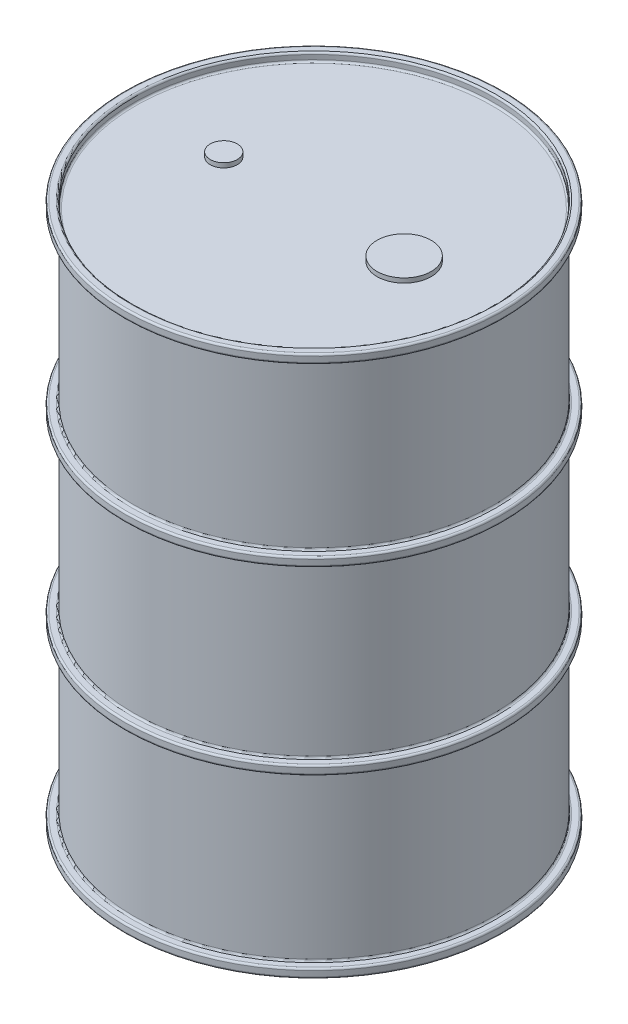
from build123d import *

# Parameters (mm, degrees)
CROQUIS1_R              = 10
SALIENTE_EXTRUIR1_DEPTH = 30
CROQUIS1_5_R            = 10.5
CROQUIS1_5_R_2          = 10
SALIENTE_EXTRUIR2_DEPTH = 0.5
SALIENTE_EXTRUIR3_START = 10
CROQUIS1_6_R            = 10.5
CROQUIS1_6_R_2          = 10
SALIENTE_EXTRUIR3_DEPTH = 0.25
SALIENTE_EXTRUIR4_START = 20
CROQUIS1_7_R            = 10.5
CROQUIS1_7_R_2          = 10
SALIENTE_EXTRUIR4_DEPTH = 0.25
SALIENTE_EXTRUIR5_START = 29.5
CROQUIS1_8_R            = 10.5
CROQUIS1_8_R_2          = 10
SALIENTE_EXTRUIR5_DEPTH = 0.5
CORTAR_EXTRUIR1_START   = -0.45
CROQUIS2_R              = 10
CORTAR_EXTRUIR1_DEPTH   = 0.45
CORTAR_EXTRUIR2_START   = -30
CROQUIS2_2_R            = 10
CORTAR_EXTRUIR2_DEPTH   = 0.45
REDONDEO2_R             = 0.1
CROQUIS3_R              = 0.75
CROQUIS3_R_2            = 1.5
SALIENTE_EXTRUIR6_DEPTH = 0.25


with BuildPart() as part:
    # Croquis1 → Saliente-Extruir1 (new body)
    with BuildSketch(Plane(origin=(0, 0, 0), x_dir=(1, 0, 0), z_dir=(0, 1, 0))):
        Circle(CROQUIS1_R)
    extrude(amount=SALIENTE_EXTRUIR1_DEPTH)

    # Croquis1_5 → Saliente-Extruir2 (add)
    with BuildSketch(Plane(origin=(0, 0, 0), x_dir=(1, 0, 0), z_dir=(0, 1, 0))):
        Circle(CROQUIS1_5_R)
        Circle(CROQUIS1_5_R_2, mode=Mode.SUBTRACT)
    extrude(amount=SALIENTE_EXTRUIR2_DEPTH)

    # Croquis1_6 → Saliente-Extruir3 (add, symmetric)
    with BuildSketch(Plane(origin=(0, 0, 0), x_dir=(1, 0, 0), z_dir=(0, 1, 0)).offset(SALIENTE_EXTRUIR3_START)):
        Circle(CROQUIS1_6_R)
        Circle(CROQUIS1_6_R_2, mode=Mode.SUBTRACT)
    extrude(amount=SALIENTE_EXTRUIR3_DEPTH, both=True)

    # Croquis1_7 → Saliente-Extruir4 (add, symmetric)
    with BuildSketch(Plane(origin=(0, 0, 0), x_dir=(1, 0, 0), z_dir=(0, 1, 0)).offset(SALIENTE_EXTRUIR4_START)):
        Circle(CROQUIS1_7_R)
        Circle(CROQUIS1_7_R_2, mode=Mode.SUBTRACT)
    extrude(amount=SALIENTE_EXTRUIR4_DEPTH, both=True)

    # Croquis1_8 → Saliente-Extruir5 (add)
    with BuildSketch(Plane(origin=(0, 0, 0), x_dir=(1, 0, 0), z_dir=(0, 1, 0)).offset(SALIENTE_EXTRUIR5_START)):
        Circle(CROQUIS1_8_R)
        Circle(CROQUIS1_8_R_2, mode=Mode.SUBTRACT)
    extrude(amount=SALIENTE_EXTRUIR5_DEPTH)

    # Croquis2 → Cortar-Extruir1 (cut)
    with BuildSketch(Plane(origin=(0, 30, 0), x_dir=(1, 0, 0), z_dir=(0, 1, 0)).offset(CORTAR_EXTRUIR1_START)):
        Circle(CROQUIS2_R)
    extrude(amount=CORTAR_EXTRUIR1_DEPTH, mode=Mode.SUBTRACT)

    # Croquis2_2 → Cortar-Extruir2 (cut)
    with BuildSketch(Plane(origin=(0, 30, 0), x_dir=(1, 0, 0), z_dir=(0, 1, 0)).offset(CORTAR_EXTRUIR2_START)):
        Circle(CROQUIS2_2_R)
    extrude(amount=CORTAR_EXTRUIR2_DEPTH, mode=Mode.SUBTRACT)

    # Redondeo2
    redondeo2_edges = [part.edges().sort_by_distance(p)[0] for p in [
        (-10, 0.45, 0),
        (-10, 0, 0),
        (-10.5, 0, 0),
        (-10.5, 0.5, 0),
        (-10, 0.5, 0),
        (-10, 9.75, 0),
        (-10.5, 9.75, 0),
        (-10.5, 10.25, 0),
        (-10, 10.25, 0),
        (-10, 19.75, 0),
        (-10.5, 19.75, 0),
        (-10.5, 20.25, 0),
        (-10, 20.25, 0),
        (-10, 29.55, 0),
        (-10, 30, 0),
        (-10.5, 30, 0),
        (-10.5, 29.5, 0),
        (-10, 29.5, 0),
    ]]
    fillet(redondeo2_edges, radius=REDONDEO2_R)

    # Croquis3 → Saliente-Extruir6 (add)
    with BuildSketch(Plane(origin=(0, 29.55, 0), x_dir=(1, 0, 0), z_dir=(0, 1, 0))):
        with Locations((-5, 0)):
            Circle(CROQUIS3_R)
        with Locations((5, 0)):
            Circle(CROQUIS3_R_2)
    extrude(amount=SALIENTE_EXTRUIR6_DEPTH)


solid = part.part
